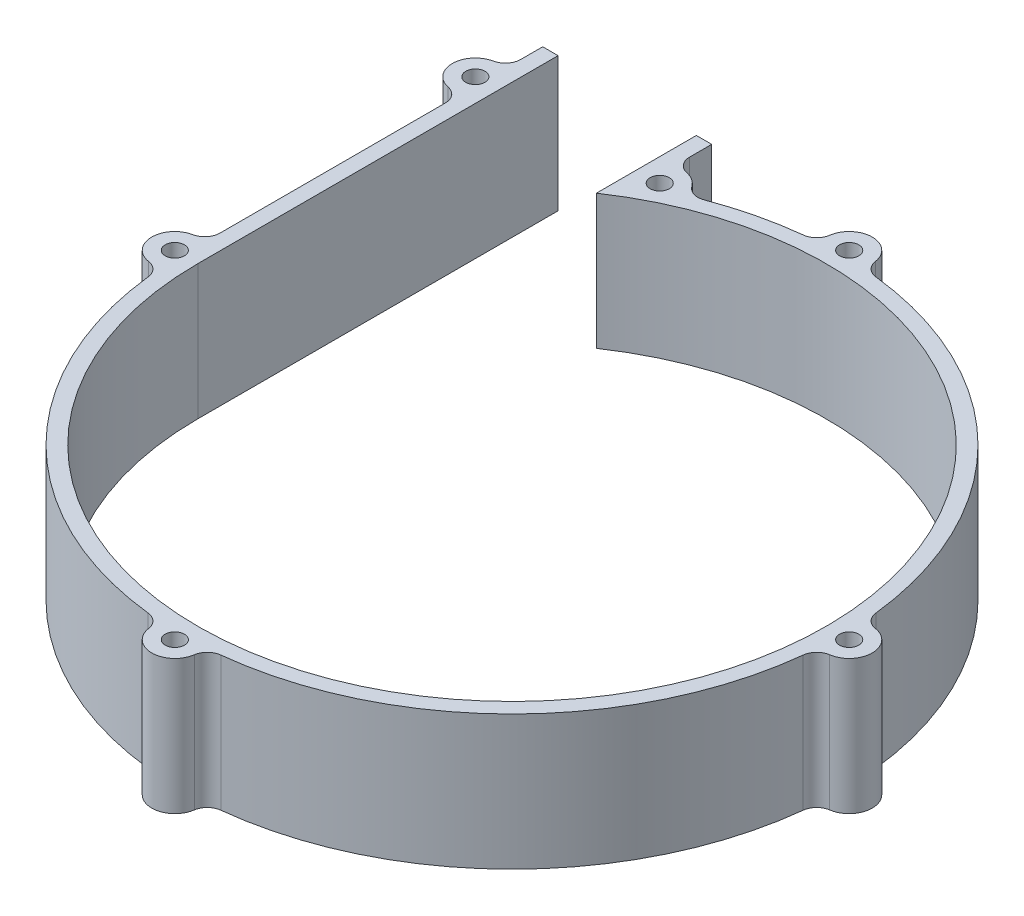
from build123d import *

# Parameters (mm, degrees)
SKETCH_1_R      = 1.25
EXTRUDE_1_DEPTH = 17.5


with BuildPart() as part:
    # 草图1 → 凸台-拉伸1 (new body)
    with BuildSketch(Plane(origin=(0, 0, 0), x_dir=(1, 0, 0), z_dir=(0, 1, 0))):
        with BuildLine():
            Line((-40.9, 0), (-40.9, 46.9))
            Line((-40.9, 46.9), (-42.9, 46.9))
            Line((-42.9, 46.9), (-42.9, 44.02953021))
            ThreePointArc((-42.9, 44.02953021), (-43.350806662, 42.764619146), (-44.5, 42.069938416))
            ThreePointArc((-44.5, 42.069938416), (-46.9, 39.130550724), (-44.5, 36.191163033))
            ThreePointArc((-44.5, 36.191163033), (-43.350806662, 35.496482303), (-42.9, 34.231571239))
            Line((-42.9, 34.231571239), (-42.9, 4.898979486))
            ThreePointArc((-42.9, 4.898979486), (-43.350806662, 3.634068421), (-44.5, 2.939387691))
            ThreePointArc((-44.5, 2.939387691), (-46.898844518, -0.083255983), (-44.335990888, -2.968149583))
            ThreePointArc((-44.335990888, -2.968149583), (-43.187596963, -3.557987573), (-42.638827361, -4.726563367))
            ThreePointArc((-42.638827361, -4.726563367), (-30.334880913, -30.334880913), (-4.726563367, -42.638827361))
            ThreePointArc((-4.726563367, -42.638827361), (-3.557987573, -43.187596963), (-2.968149583, -44.335990888))
            ThreePointArc((-2.968149583, -44.335990888), (0, -46.9), (2.968149583, -44.335990888))
            ThreePointArc((2.968149583, -44.335990888), (3.557987573, -43.187596963), (4.726563367, -42.638827361))
            ThreePointArc((4.726563367, -42.638827361), (30.334880913, -30.334880913), (42.638827361, -4.726563367))
            ThreePointArc((42.638827361, -4.726563367), (43.187596963, -3.557987573), (44.335990888, -2.968149583))
            ThreePointArc((44.335990888, -2.968149583), (46.9, 0), (44.335990888, 2.968149583))
            ThreePointArc((44.335990888, 2.968149583), (43.187596963, 3.557987573), (42.638827361, 4.726563367))
            ThreePointArc((42.638827361, 4.726563367), (30.334880913, 30.334880913), (4.726563367, 42.638827361))
            ThreePointArc((4.726563367, 42.638827361), (3.557987573, 43.187596963), (2.968149583, 44.335990888))
            ThreePointArc((2.968149583, 44.335990888), (0, 46.9), (-2.968149583, 44.335990888))
            ThreePointArc((-2.968149583, 44.335990888), (-3.557987573, 43.187596963), (-4.726563367, 42.638827361))
            ThreePointArc((-4.726563367, 42.638827361), (-9.998714121, 41.718529647), (-15.115253688, 40.148961455))
            ThreePointArc((-15.115253688, 40.148961455), (-16.405630214, 40.108391944), (-17.451956512, 40.864645036))
            ThreePointArc((-17.451956512, 40.864645036), (-18.261151224, 41.643352884), (-19.3, 42.069938416))
            ThreePointArc((-19.3, 42.069938416), (-20.449193338, 42.764619146), (-20.9, 44.02953021))
            Line((-20.9, 44.02953021), (-20.9, 46.9))
            Line((-20.9, 46.9), (-22.9, 46.9))
            Line((-22.9, 46.9), (-22.9, 33.888050991))
            ThreePointArc((-22.9, 33.888050991), (36.120769649, -19.185932346), (-40.9, 0))
        make_face()
        with Locations((0, 43.9)):
            Circle(SKETCH_1_R, mode=Mode.SUBTRACT)
        with Locations((43.9, 0)):
            Circle(SKETCH_1_R, mode=Mode.SUBTRACT)
        with Locations((0, -43.9)):
            Circle(SKETCH_1_R, mode=Mode.SUBTRACT)
        with Locations((-43.9, 0)):
            Circle(SKETCH_1_R, mode=Mode.SUBTRACT)
        with Locations((-19.9, 39.130550724)):
            Circle(SKETCH_1_R, mode=Mode.SUBTRACT)
        with Locations((-43.9, 39.130550724)):
            Circle(SKETCH_1_R, mode=Mode.SUBTRACT)
    extrude(amount=EXTRUDE_1_DEPTH)


solid = part.part
